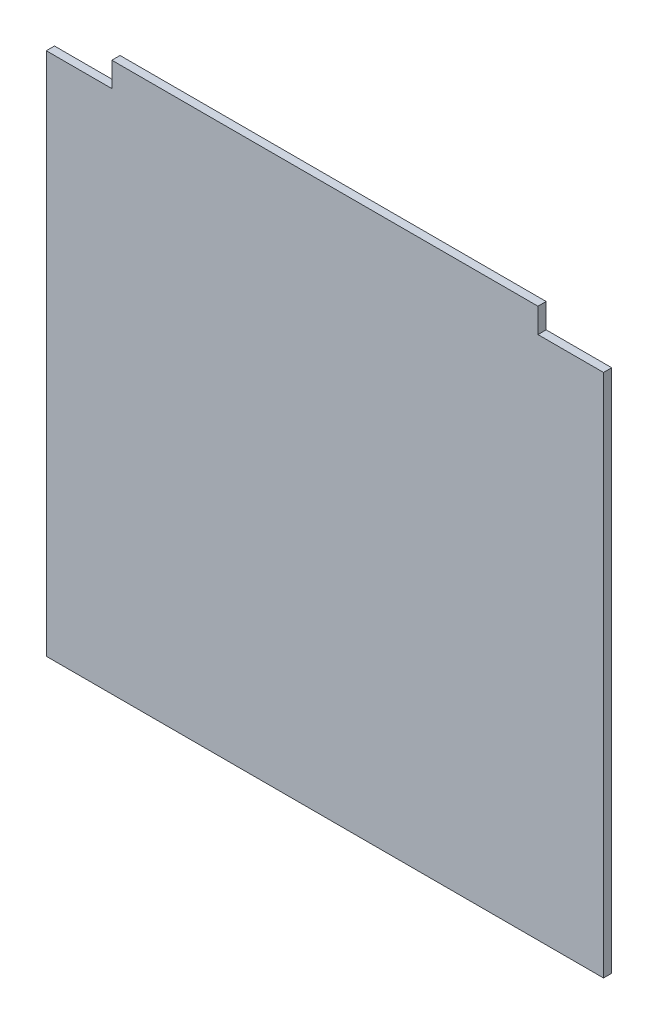
from build123d import *

# Parameters (mm, degrees)
ESQUISSE1_W             = 680
ESQUISSE1_H             = 670
BOSS_EXTRU_1_DEPTH      = 10
ESQUISSE2_W             = 80
ESQUISSE2_H             = 30
ENL_V_MAT_EXTRU_1_DEPTH = 11


with BuildPart() as part:
    # Esquisse1 → Boss.-Extru.1 (new body)
    with BuildSketch(Plane.XY):
        Rectangle(ESQUISSE1_W, ESQUISSE1_H)
    extrude(amount=BOSS_EXTRU_1_DEPTH)

    # Esquisse2 → Enlèv. mat.-Extru.1 (cut, through all)
    with BuildSketch(Plane.XY.offset(10)):
        with Locations((-300, 320)):
            Rectangle(ESQUISSE2_W, ESQUISSE2_H)
        with Locations((300, 320)):
            Rectangle(ESQUISSE2_W, ESQUISSE2_H)
    extrude(amount=-ENL_V_MAT_EXTRU_1_DEPTH, mode=Mode.SUBTRACT)


solid = part.part
